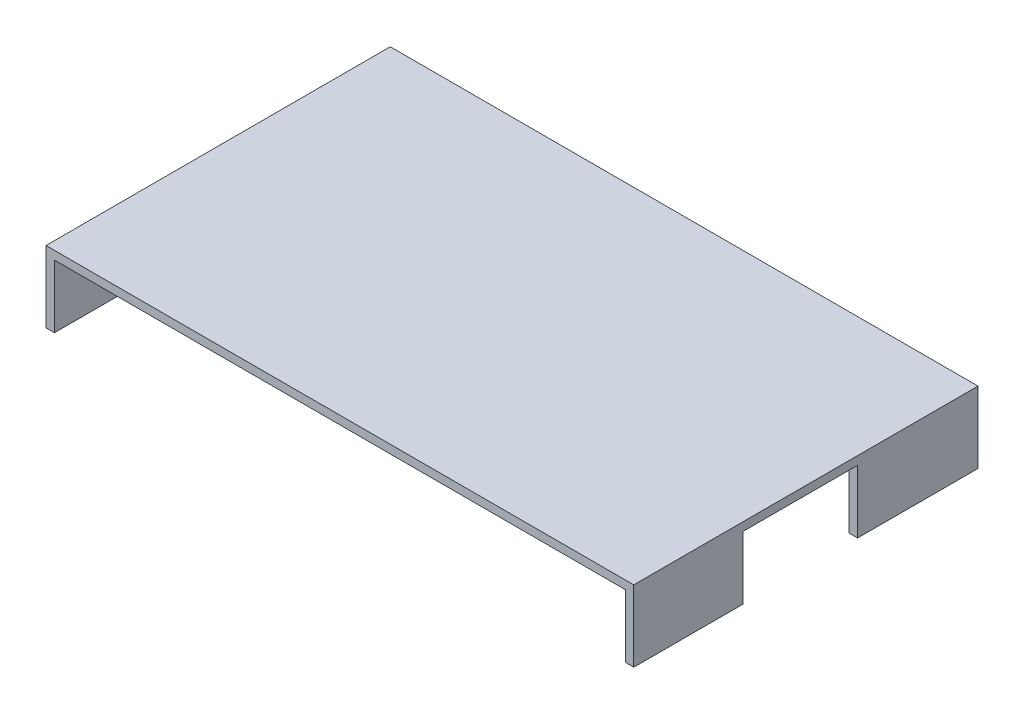
from build123d import *

# Parameters (mm, degrees)
EXTRUDE_1_DEPTH     = 2
SKETCH_2_W          = 2
SKETCH_2_H          = 82
EXTRUDE_2_DEPTH     = 15
CUT_EXTRUDE_2_DEPTH = 20


with BuildPart() as part:
    # 草图1 → 凸台-拉伸1 (new body)
    with BuildSketch(Plane(origin=(0, 0, 0), x_dir=(1, 0, 0), z_dir=(0, 1, 0))):
        Polygon((0, -41), (70, -41), (70, -6.017578489), (70, 41), (0, 41), (-70, 41), (-70, 0), (-70, -41), align=None)
    extrude(amount=EXTRUDE_1_DEPTH)

    # 草图2 → 凸台-拉伸2 (add)
    with BuildSketch(Plane.XZ):
        with Locations((-69, 0)):
            Rectangle(SKETCH_2_W, SKETCH_2_H)
        with Locations((69, 0)):
            Rectangle(SKETCH_2_W, SKETCH_2_H)
    extrude(amount=EXTRUDE_2_DEPTH)

    # 草图4 → 切除-拉伸2 (cut)
    with BuildSketch(Plane(origin=(70, 0, 0), x_dir=(0, 0, -1), z_dir=(1, 0, 0))):
        Polygon((0, 0), (-14.99, 0), (-14.99, -15), (12.32, -15), (12.32, 0), align=None)
    extrude(amount=-CUT_EXTRUDE_2_DEPTH, mode=Mode.SUBTRACT)


solid = part.part
